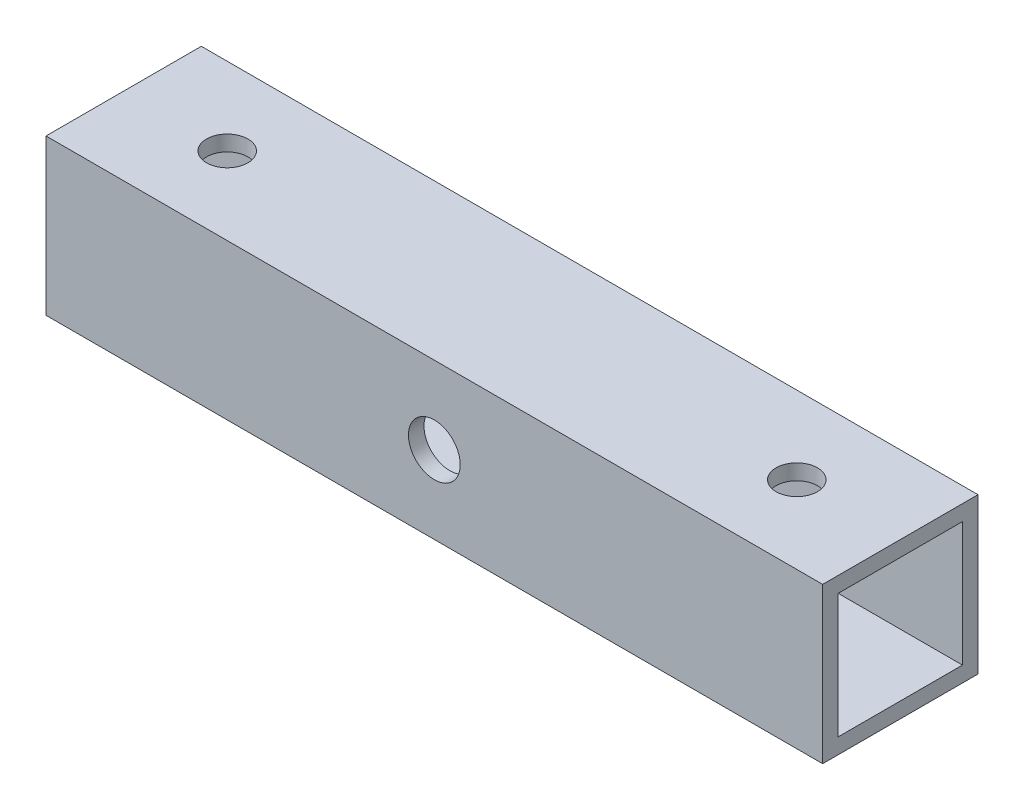
from build123d import *

# Parameters (mm, degrees)
SKETCH1_W           = 150
SKETCH1_H           = 30
BOSS_EXTRUDE1_DEPTH = 30
SHELL1_T            = -3
SKETCH2_R           = 5
CUT_EXTRUDE1_DEPTH  = 30
SKETCH3_R           = 4
CUT_EXTRUDE2_DEPTH  = 36


with BuildPart() as part:
    # Sketch1 → Boss-Extrude1 (new body)
    with BuildSketch(Plane.XY):
        Rectangle(SKETCH1_W, SKETCH1_H)
    extrude(amount=BOSS_EXTRUDE1_DEPTH)

    # Shell1
    shell1_openings = [part.faces().sort_by_distance(p)[0] for p in [
        (-75, 0, 15),
        (75, 0, 15),
    ]]
    offset(amount=SHELL1_T, openings=shell1_openings, kind=Kind.INTERSECTION)

    # Sketch2 → Cut-Extrude1 (cut)
    with BuildSketch(Plane.XY.offset(30)):
        Circle(SKETCH2_R)
    extrude(amount=-CUT_EXTRUDE1_DEPTH, mode=Mode.SUBTRACT)

    # Sketch3 → Cut-Extrude2 (cut)
    with BuildSketch(Plane(origin=(0, 15, 0), x_dir=(1, 0, 0), z_dir=(0, 1, 0))):
        with Locations((-55, -15)):
            Circle(SKETCH3_R)
        with Locations((55, -15)):
            Circle(SKETCH3_R)
    extrude(amount=-CUT_EXTRUDE2_DEPTH, mode=Mode.SUBTRACT)


solid = part.part
